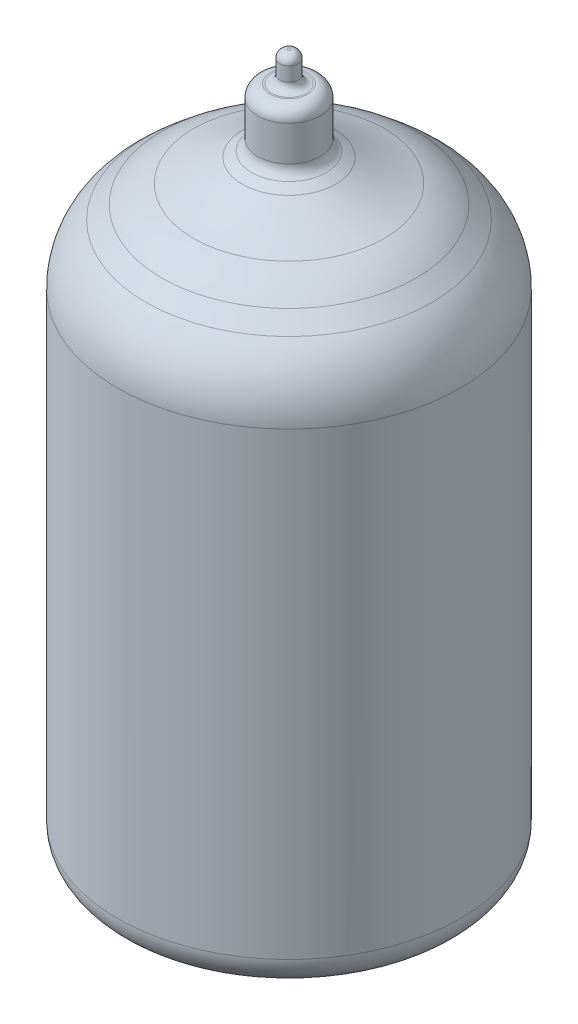
from build123d import *

# Parameters (mm, degrees)
FILLET1_R = 5
FILLET2_R = 7
SHELL1_T  = -0.6


with BuildPart() as part:
    # Sketch1 → Revolve1 (revolve)
    with BuildSketch(Plane(origin=(0, 0, 0), x_dir=(0, 0, -1), z_dir=(1, 0, 0)), mode=Mode.PRIVATE) as revolve1_sk:
        with BuildLine():
            Line((11, 35), (11, 3.206399783))
            Line((11, 3.206399783), (0, 3.206399783))
            Line((0, 3.206399783), (0, 39.972316521))
            Line((0, 39.972316521), (3, 39.972316521))
            ThreePointArc((3, 39.972316521), (5.032601016, 38.948328053), (7.168380233, 38.161901699))
            Line((7.168380233, 38.161901699), (11, 35))
        make_face()
    revolve(revolve1_sk.sketch.rotate(Axis((0, 41.810612358, 0), (0, -1, 0)), 180), axis=Axis((0, 41.810612358, 0), (0, -1, 0)))

    # Fillet1
    fillet1_edges = [part.edges().sort_by_distance(p)[0] for p in [
        (0, 35, -11),
    ]]
    fillet(fillet1_edges, radius=FILLET1_R)

    # Fillet2
    fillet2_edges = [part.edges().sort_by_distance(p)[0] for p in [
        (0, 38.161901699, -7.168380233),
    ]]
    fillet(fillet2_edges, radius=FILLET2_R)

    # Shell1
    shell1_openings = [part.faces().sort_by_distance(p)[0] for p in [
        (0, 3.206399783, 0),
    ]]
    offset(amount=SHELL1_T, openings=shell1_openings, kind=Kind.INTERSECTION)

    # Sketch2 → Revolve2 (revolve)
    with BuildSketch(Plane(origin=(0, 0, 0), x_dir=(0, -1, 0), z_dir=(1, 0, 0)), mode=Mode.PRIVATE) as revolve2_sk:
        with BuildLine():
            Line((-39.972316521, 3), (-40.318726682, 2.4))
            ThreePointArc((-40.318726682, 2.4), (-40.611547005, 2.107179677), (-41.011547005, 2))
            Line((-41.011547005, 2), (-43.272316521, 2))
            ThreePointArc((-43.272316521, 2), (-43.838001946, 1.765685425), (-44.072316521, 1.2))
            Line((-44.072316521, 1.2), (-44.072316521, 1.1))
            ThreePointArc((-44.072316521, 1.1), (-44.21876313, 0.746446609), (-44.572316521, 0.6))
            Line((-44.572316521, 0.6), (-45.472316521, 0.6))
            ThreePointArc((-45.472316521, 0.6), (-45.825869911, 0.453553391), (-45.972316521, 0.1))
            Line((-45.972316521, 0.1), (-45.972316521, 0))
            Line((-45.972316521, 0), (-39.972316521, 0))
            Line((-39.972316521, 0), (-39.972316521, 3))
        make_face()
    revolve(revolve2_sk.sketch.rotate(Axis((0, 46.272316521, 0), (0, -1, 0)), 180), axis=Axis((0, 46.272316521, 0), (0, -1, 0)))

    # Sketch3 → Revolve3 (revolve)
    with BuildSketch(Plane.XY, mode=Mode.PRIVATE) as revolve3_sk:
        with BuildLine():
            Line((0, 0), (-5.785451419, 0))
            ThreePointArc((-5.785451419, 0), (-6.132747775, 0.030384494), (-6.469491706, 0.120614758))
            Line((-6.469491706, 0.120614758), (-9.684040287, 1.290614758))
            ThreePointArc((-9.684040287, 1.290614758), (-10.638304089, 2.022847127), (-11, 3.17))
            Line((-11, 3.17), (-11, 3.206399783))
            Line((-11, 3.206399783), (-10.4, 3.206399783))
            Line((-10.4, 3.206399783), (-10.4, 3.12))
            ThreePointArc((-10.4, 3.12), (-10.282842712, 2.837157288), (-10, 2.72))
            Line((-10, 2.72), (0, 2.72))
            Line((0, 2.72), (0, 0))
        make_face()
    revolve(revolve3_sk.sketch.rotate(Axis((0, 3.366719772, 0), (0, -1, 0)), 270), axis=Axis((0, 3.366719772, 0), (0, -1, 0)))

    # Sketch4 → Revolve4 (revolve)
    with BuildSketch(Plane(origin=(0, 0, 0), x_dir=(0.809016994, 0, 0.587785252), z_dir=(-0.587785252, 0, 0.809016994)), mode=Mode.PRIVATE) as revolve4_sk:
        with BuildLine():
            Line((7.65, 2), (6.945451842, 4.629409523))
            ThreePointArc((6.945451842, 4.629409523), (6.766869643, 4.89667667), (6.462488929, 5))
            Line((6.462488929, 5), (5.95, 5))
            Line((5.95, 5), (5.95, 2))
            Line((5.95, 2), (7.65, 2))
        make_face()
    revolve(revolve4_sk.sketch.rotate(Axis((4.813651117, 1.85, 3.497322251), (0, 1, 0)), 126), axis=Axis((4.813651117, 1.85, 3.497322251), (0, 1, 0)))

    # Sketch5 → Revolve5 (revolve)
    with BuildSketch(Plane(origin=(0, 0, 0), x_dir=(0.309016994, 0, 0.951056516), z_dir=(-0.951056516, 0, 0.309016994)), mode=Mode.PRIVATE) as revolve5_sk:
        with BuildLine():
            Line((7.65, 2), (6.945451842, 4.629409523))
            ThreePointArc((6.945451842, 4.629409523), (6.766869643, 4.89667667), (6.462488929, 5))
            Line((6.462488929, 5), (5.95, 5))
            Line((5.95, 5), (5.95, 2))
            Line((5.95, 2), (7.65, 2))
        make_face()
    revolve(revolve5_sk.sketch.rotate(Axis((1.838651117, 1.85, 5.658786272), (0, 1, 0)), 72), axis=Axis((1.838651117, 1.85, 5.658786272), (0, 1, 0)))

    # Sketch6 → Revolve6 (revolve)
    with BuildSketch(Plane(origin=(0, 0, 0), x_dir=(-0.309016994, 0, 0.951056516), z_dir=(-0.951056516, 0, -0.309016994)), mode=Mode.PRIVATE) as revolve6_sk:
        with BuildLine():
            Line((7.65, 2), (6.945451842, 4.629409523))
            ThreePointArc((6.945451842, 4.629409523), (6.766869643, 4.89667667), (6.462488929, 5))
            Line((6.462488929, 5), (5.95, 5))
            Line((5.95, 5), (5.95, 2))
            Line((5.95, 2), (7.65, 2))
        make_face()
    revolve(revolve6_sk.sketch.rotate(Axis((-1.838651117, 1.85, 5.658786272), (0, 1, 0)), 108), axis=Axis((-1.838651117, 1.85, 5.658786272), (0, 1, 0)))

    # Sketch7 → Revolve7 (revolve)
    with BuildSketch(Plane(origin=(0, 0, 0), x_dir=(-0.809016994, 0, 0.587785252), z_dir=(-0.587785252, 0, -0.809016994)), mode=Mode.PRIVATE) as revolve7_sk:
        with BuildLine():
            Line((7.65, 2), (6.945451842, 4.629409523))
            ThreePointArc((6.945451842, 4.629409523), (6.766869643, 4.89667667), (6.462488929, 5))
            Line((6.462488929, 5), (5.95, 5))
            Line((5.95, 5), (5.95, 2))
            Line((5.95, 2), (7.65, 2))
        make_face()
    revolve(revolve7_sk.sketch.rotate(Axis((-4.813651117, 1.85, 3.497322251), (0, 1, 0)), 234), axis=Axis((-4.813651117, 1.85, 3.497322251), (0, 1, 0)))

    # Sketch8 → Revolve8 (revolve)
    with BuildSketch(Plane(origin=(0, 0, 0), x_dir=(-1, 0, 0), z_dir=(0, 0, -1)), mode=Mode.PRIVATE) as revolve8_sk:
        with BuildLine():
            Line((7.65, 2), (6.945451842, 4.629409523))
            ThreePointArc((6.945451842, 4.629409523), (6.766869643, 4.89667667), (6.462488929, 5))
            Line((6.462488929, 5), (5.95, 5))
            Line((5.95, 5), (5.95, 2))
            Line((5.95, 2), (7.65, 2))
        make_face()
    revolve(revolve8_sk.sketch.rotate(Axis((-5.95, 1.85, 0), (0, 1, 0)), 270), axis=Axis((-5.95, 1.85, 0), (0, 1, 0)))

    # Sketch9 → Revolve9 (revolve)
    with BuildSketch(Plane(origin=(0, 0, 0), x_dir=(-0.809016994, 0, -0.587785252), z_dir=(0.587785252, 0, -0.809016994)), mode=Mode.PRIVATE) as revolve9_sk:
        with BuildLine():
            Line((7.65, 2), (6.945451842, 4.629409523))
            ThreePointArc((6.945451842, 4.629409523), (6.766869643, 4.89667667), (6.462488929, 5))
            Line((6.462488929, 5), (5.95, 5))
            Line((5.95, 5), (5.95, 2))
            Line((5.95, 2), (7.65, 2))
        make_face()
    revolve(revolve9_sk.sketch.rotate(Axis((-4.813651117, 1.85, -3.497322251), (0, 1, 0)), 306), axis=Axis((-4.813651117, 1.85, -3.497322251), (0, 1, 0)))

    # Sketch10 → Revolve10 (revolve)
    with BuildSketch(Plane(origin=(0, 0, 0), x_dir=(-0.309016994, 0, -0.951056516), z_dir=(0.951056516, 0, -0.309016994)), mode=Mode.PRIVATE) as revolve10_sk:
        with BuildLine():
            Line((7.65, 2), (6.945451842, 4.629409523))
            ThreePointArc((6.945451842, 4.629409523), (6.766869643, 4.89667667), (6.462488929, 5))
            Line((6.462488929, 5), (5.95, 5))
            Line((5.95, 5), (5.95, 2))
            Line((5.95, 2), (7.65, 2))
        make_face()
    revolve(revolve10_sk.sketch.rotate(Axis((-1.838651117, 1.85, -5.658786272), (0, 1, 0)), 252), axis=Axis((-1.838651117, 1.85, -5.658786272), (0, 1, 0)))

    # Sketch11 → Revolve11 (revolve)
    with BuildSketch(Plane(origin=(0, 0, 0), x_dir=(0.309016994, 0, -0.951056516), z_dir=(0.951056516, 0, 0.309016994)), mode=Mode.PRIVATE) as revolve11_sk:
        with BuildLine():
            Line((7.65, 2), (6.945451842, 4.629409523))
            ThreePointArc((6.945451842, 4.629409523), (6.766869643, 4.89667667), (6.462488929, 5))
            Line((6.462488929, 5), (5.95, 5))
            Line((5.95, 5), (5.95, 2))
            Line((5.95, 2), (7.65, 2))
        make_face()
    revolve(revolve11_sk.sketch.rotate(Axis((1.838651117, 1.85, -5.658786272), (0, 1, 0)), 288), axis=Axis((1.838651117, 1.85, -5.658786272), (0, 1, 0)))

    # Sketch12 → Revolve12 (revolve)
    with BuildSketch(Plane(origin=(0, 0, 0), x_dir=(0.809016994, 0, -0.587785252), z_dir=(0.587785252, 0, 0.809016994)), mode=Mode.PRIVATE) as revolve12_sk:
        with BuildLine():
            Line((7.65, 2), (6.945451842, 4.629409523))
            ThreePointArc((6.945451842, 4.629409523), (6.766869643, 4.89667667), (6.462488929, 5))
            Line((6.462488929, 5), (5.95, 5))
            Line((5.95, 5), (5.95, 2))
            Line((5.95, 2), (7.65, 2))
        make_face()
    revolve(revolve12_sk.sketch.rotate(Axis((4.813651117, 1.85, -3.497322251), (0, 1, 0)), 54), axis=Axis((4.813651117, 1.85, -3.497322251), (0, 1, 0)))


solid = part.part
